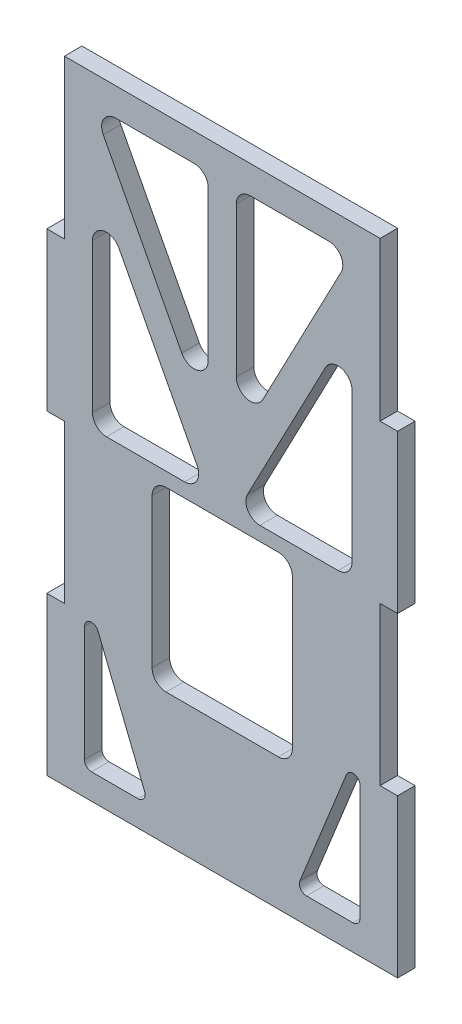
from build123d import *

# Parameters (mm, degrees)
BOSS_EXTRUDE1_DEPTH = 3.175
FILLET1_R           = 1.27


with BuildPart() as part:
    # Sketch1 → Boss-Extrude1 (new body)
    with BuildSketch(Plane.XY):
        Polygon((35.620689733, 40.579771036), (38.795689733, 40.579771036), (38.795689733, 69.2403508), (95.945689733, 69.2403508), (95.945689733, 40.579771036), (99.120689733, 40.579771036), (99.120689733, 12.004771036), (95.945689733, 12.004771036), (95.945689733, -16.570228964), (99.120689733, -16.570228964), (99.120689733, -45.145228964), (95.945689733, -45.145228964), (38.795689733, -45.145228964), (35.620689733, -45.145228964), (35.620689733, -16.570228964), (38.795689733, -16.570228964), (38.795689733, 12.004771036), (35.620689733, 12.004771036), align=None)
        with BuildLine():
            Line((48.079687467, 64.1603508), (62.290689733, 64.1603508))
            ThreePointArc((62.290689733, 64.1603508), (64.086740957, 63.416402024), (64.830689733, 61.6203508))
            Line((64.830689733, 61.6203508), (64.830689733, 34.490159477))
            ThreePointArc((64.830689733, 34.490159477), (62.89755253, 32.023721246), (60.040675918, 33.311584986))
            Line((60.040675918, 33.311584986), (45.829673652, 60.441776309))
            ThreePointArc((45.829673652, 60.441776309), (45.90653547, 62.935269199), (48.079687467, 64.1603508))
        make_face(mode=Mode.SUBTRACT)
        with BuildLine():
            Line((69.910689733, 61.6203508), (69.910689733, 34.490159477))
            ThreePointArc((69.910689733, 34.490159477), (71.843826936, 32.023721246), (74.700703548, 33.311584986))
            Line((74.700703548, 33.311584986), (88.911705815, 60.441776309))
            ThreePointArc((88.911705815, 60.441776309), (88.834843997, 62.935269199), (86.661691999, 64.1603508))
            Line((86.661691999, 64.1603508), (72.450689733, 64.1603508))
            ThreePointArc((72.450689733, 64.1603508), (70.654638509, 63.416402024), (69.910689733, 61.6203508))
        make_face(mode=Mode.SUBTRACT)
        with BuildLine():
            Line((43.875689733, 42.900802499), (43.875689733, 15.9003508))
            ThreePointArc((43.875689733, 15.9003508), (44.619638509, 14.104299576), (46.415689733, 13.3603508))
            Line((46.415689733, 13.3603508), (60.558733389, 13.3603508))
            ThreePointArc((60.558733389, 13.3603508), (62.731885387, 14.585432401), (62.808747205, 17.078925291))
            Line((62.808747205, 17.078925291), (48.665703548, 44.07937699))
            ThreePointArc((48.665703548, 44.07937699), (45.808826936, 45.36724073), (43.875689733, 42.900802499))
        make_face(mode=Mode.SUBTRACT)
        with BuildLine():
            Line((71.932632262, 17.078925291), (86.075675918, 44.07937699))
            ThreePointArc((86.075675918, 44.07937699), (88.93255253, 45.36724073), (90.865689733, 42.900802499))
            Line((90.865689733, 42.900802499), (90.865689733, 15.9003508))
            ThreePointArc((90.865689733, 15.9003508), (90.121740957, 14.104299576), (88.325689733, 13.3603508))
            Line((88.325689733, 13.3603508), (74.182646077, 13.3603508))
            ThreePointArc((74.182646077, 13.3603508), (72.00949408, 14.585432401), (71.932632262, 17.078925291))
        make_face(mode=Mode.SUBTRACT)
        with BuildLine():
            Line((57.210689733, 10.8203508), (77.530689733, 10.8203508))
            ThreePointArc((77.530689733, 10.8203508), (79.326740957, 10.076402024), (80.070689733, 8.2803508))
            Line((80.070689733, 8.2803508), (80.070689733, -18.725228972))
            ThreePointArc((80.070689733, -18.725228972), (79.326740957, -20.521280196), (77.530689733, -21.265228972))
            Line((77.530689733, -21.265228972), (57.210689733, -21.265228972))
            ThreePointArc((57.210689733, -21.265228972), (55.414638509, -20.521280196), (54.670689733, -18.725228972))
            Line((54.670689733, -18.725228972), (54.670689733, 8.2803508))
            ThreePointArc((54.670689733, 8.2803508), (55.414638509, 10.076402024), (57.210689733, 10.8203508))
        make_face(mode=Mode.SUBTRACT)
        Polygon((42.432285336, -11.806981605), (42.432285336, -40.525537031), (54.020897102, -40.525537031), align=None, mode=Mode.SUBTRACT)
        Polygon((92.30909413, -40.525537031), (80.720482364, -40.525537031), (92.30909413, -11.806981605), align=None, mode=Mode.SUBTRACT)
    extrude(amount=BOSS_EXTRUDE1_DEPTH)

    # Fillet1
    fillet1_edges = [part.edges().sort_by_distance(p)[0] for p in [
        (54.020897102, -40.525537031, 1.5875),
        (42.432285336, -11.806981605, 1.5875),
        (42.432285336, -40.525537031, 1.5875),
        (92.30909413, -40.525537031, 1.5875),
        (92.30909413, -11.806981605, 1.5875),
        (80.720482364, -40.525537031, 1.5875),
    ]]
    fillet(fillet1_edges, radius=FILLET1_R)


solid = part.part
